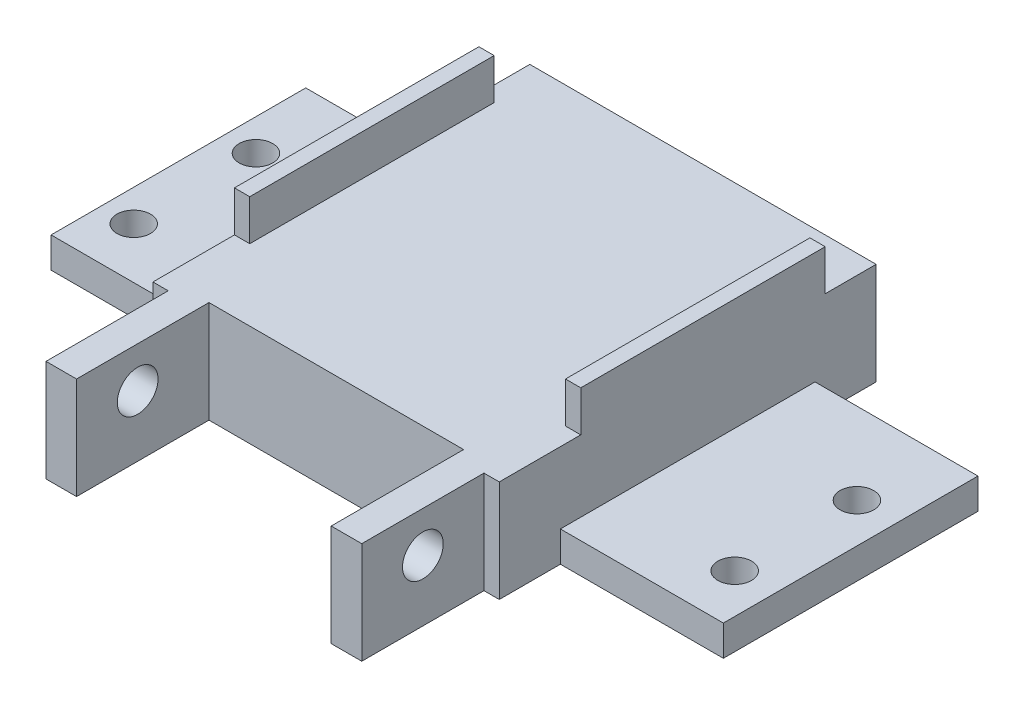
from build123d import *

# Parameters (mm, degrees)
SKETCH_1_W          = 34
SKETCH_1_H          = 49
EXTRUDE_1_DEPTH     = 10
SKETCH_2_W          = 1.5
SKETCH_2_H          = 24
EXTRUDE_2_DEPTH     = 4
SKETCH_3_W          = 1.5
SKETCH_3_H          = 12
SKETCH_3_W_2        = 25
SKETCH_3_H_2        = 13
CUT_EXTRUDE_1_DEPTH = 10
SKETCH_4_R          = 2
CUT_EXTRUDE_2_DEPTH = 31
EXTRUDE_3_DEPTH     = 8
CUT_EXTRUDE_4_DEPTH = 10
SKETCH_6_W          = 16
SKETCH_6_H          = 25
EXTRUDE_4_DEPTH     = 3
SKETCH_7_R          = 1.65
CUT_EXTRUDE_5_DEPTH = 8


with BuildPart() as part:
    # 草图1 → 凸台-拉伸1 (new body)
    with BuildSketch(Plane(origin=(0, 0, 0), x_dir=(1, 0, 0), z_dir=(0, 1, 0))):
        Rectangle(SKETCH_1_W, SKETCH_1_H)
    extrude(amount=EXTRUDE_1_DEPTH)

    # 草图2 → 凸台-拉伸2 (add)
    with BuildSketch(Plane(origin=(0, 10, 0), x_dir=(1, 0, 0), z_dir=(0, 1, 0))):
        with Locations((-16.25, 7.5)):
            Rectangle(SKETCH_2_W, SKETCH_2_H)
        with Locations((16.25, 7.5)):
            Rectangle(SKETCH_2_W, SKETCH_2_H)
    extrude(amount=EXTRUDE_2_DEPTH)

    # 草图3 → 切除-拉伸1 (cut)
    with BuildSketch(Plane(origin=(0, 10, 0), x_dir=(1, 0, 0), z_dir=(0, 1, 0))):
        with Locations((-16.25, -18.5)):
            Rectangle(SKETCH_3_W, SKETCH_3_H)
        with Locations((16.25, -18.5)):
            Rectangle(SKETCH_3_W, SKETCH_3_H)
        with Locations((0, -18)):
            Rectangle(SKETCH_3_W_2, SKETCH_3_H_2)
    extrude(amount=-CUT_EXTRUDE_1_DEPTH, mode=Mode.SUBTRACT)

    # 草图4 → 切除-拉伸2 (cut)
    with BuildSketch(Plane.ZY.offset(15.5)):
        with Locations((18.5, 6)):
            Circle(SKETCH_4_R)
    extrude(amount=-CUT_EXTRUDE_2_DEPTH, mode=Mode.SUBTRACT)

    # 草图5 → 凸台-拉伸3 (add)
    with BuildSketch(Plane.XZ):
        Polygon((4, 11.5), (-4, 11.5), (-4, 41.5), (-13, 41.5), (-13, 56.5), (13, 56.5), (13, 41.5), (4, 41.5), align=None)
    extrude(amount=-EXTRUDE_3_DEPTH)

    # 草图5<2> → 切除-拉伸4 (cut)
    with BuildSketch(Plane.XZ):
        Polygon((4, 11.5), (-4, 11.5), (-4, 41.5), (-13, 41.5), (-13, 56.5), (13, 56.5), (13, 41.5), (4, 41.5), align=None)
    extrude(amount=-CUT_EXTRUDE_4_DEPTH, mode=Mode.SUBTRACT)

    # 草图6 → 凸台-拉伸4 (add)
    with BuildSketch(Plane.XZ):
        with Locations((25, -6)):
            Rectangle(SKETCH_6_W, SKETCH_6_H)
        with Locations((-25, -6)):
            Rectangle(SKETCH_6_W, SKETCH_6_H)
    extrude(amount=-EXTRUDE_4_DEPTH)

    # 草图7 → 切除-拉伸5 (cut)
    with BuildSketch(Plane.XZ):
        with Locations((29.112405101, 1.5)):
            Circle(SKETCH_7_R)
        with Locations((29.112405101, -10.5)):
            Circle(SKETCH_7_R)
        with Locations((-29.887594899, 1.5)):
            Circle(SKETCH_7_R)
        with Locations((-29.887594899, -10.5)):
            Circle(SKETCH_7_R)
    extrude(amount=-CUT_EXTRUDE_5_DEPTH, mode=Mode.SUBTRACT)


solid = part.part
